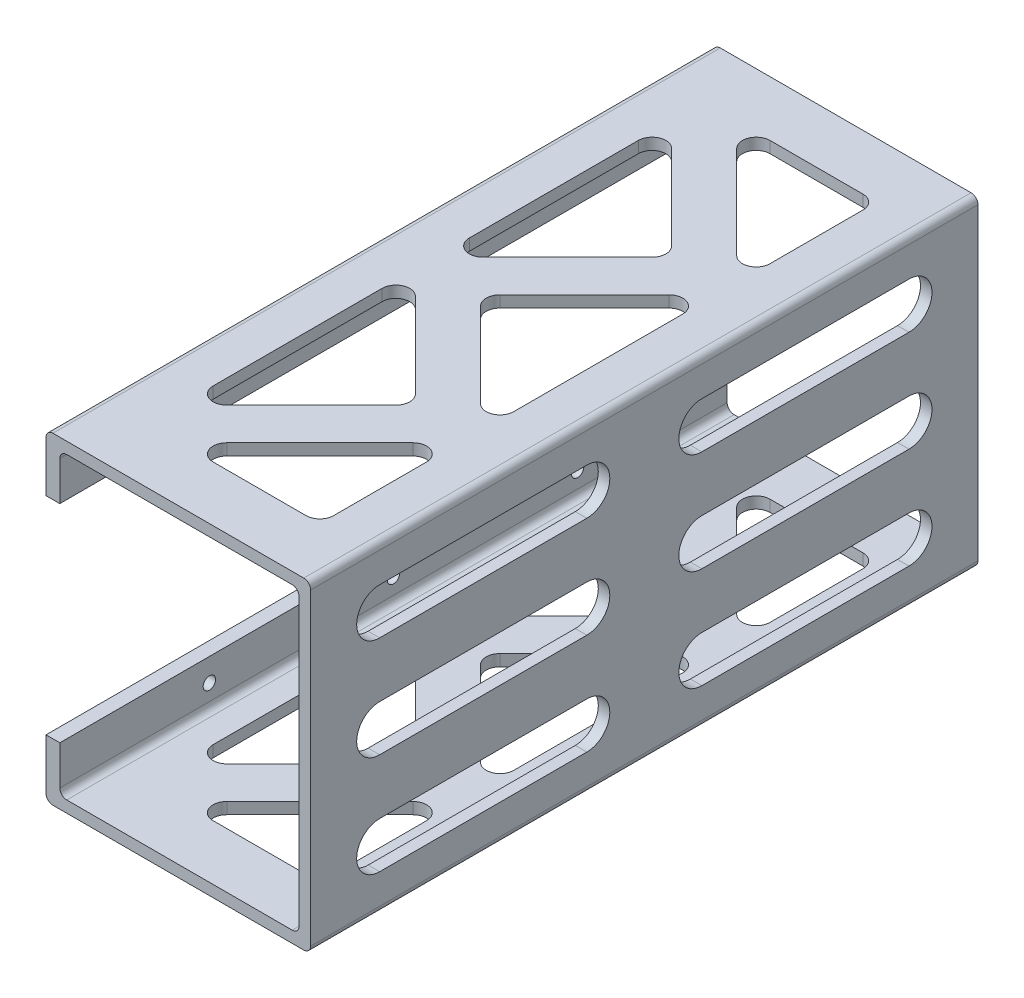
from build123d import *

# Parameters (mm, degrees)
EXTRUDE_1_DEPTH     = 145
SKETCH_2_R          = 1.35
CUT_EXTRUDE_1_DEPTH = 3
CUT_EXTRUDE_2_DEPTH = 2.5
CUT_EXTRUDE_3_DEPTH = 70
FILLET_1_R          = 3
FILLET_2_R          = 1.5


with BuildPart() as part:
    # 草图1 → 凸台-拉伸1 (new body)
    with BuildSketch(Plane.XY):
        Polygon((0, 57.5), (0, 70), (57.5, 70), (57.5, 0), (0, 0), (0, 12.5), (3, 12.5), (3, 2.5), (55, 2.5), (55, 67.5), (3, 67.5), (3, 57.5), align=None)
    extrude(amount=-EXTRUDE_1_DEPTH)

    # 草图2 → 切除-拉伸1 (cut)
    with BuildSketch(Plane.ZY):
        with Locations((-112.5, 62.5)):
            Circle(SKETCH_2_R)
        with Locations((-72.5, 62.5)):
            Circle(SKETCH_2_R)
        with Locations((-32.5, 62.5)):
            Circle(SKETCH_2_R)
        with Locations((-32.5, 7.5)):
            Circle(SKETCH_2_R)
        with Locations((-72.5, 7.5)):
            Circle(SKETCH_2_R)
        with Locations((-112.5, 7.5)):
            Circle(SKETCH_2_R)
    extrude(amount=-CUT_EXTRUDE_1_DEPTH, mode=Mode.SUBTRACT)

    # 草图3 → 切除-拉伸2 (cut)
    with BuildSketch(Plane.ZY.offset(-55)):
        with BuildLine():
            Line((-130, 62), (-85, 62))
            ThreePointArc((-85, 62), (-80, 57), (-85, 52))
            Line((-85, 52), (-130, 52))
            ThreePointArc((-130, 52), (-135, 57), (-130, 62))
        make_face()
        with BuildLine():
            Line((-130, 40), (-85, 40))
            ThreePointArc((-85, 40), (-80, 35), (-85, 30))
            Line((-85, 30), (-130, 30))
            ThreePointArc((-130, 30), (-135, 35), (-130, 40))
        make_face()
        with BuildLine():
            Line((-130, 18), (-85, 18))
            ThreePointArc((-85, 18), (-80, 13), (-85, 8))
            Line((-85, 8), (-130, 8))
            ThreePointArc((-130, 8), (-135, 13), (-130, 18))
        make_face()
        with BuildLine():
            Line((-60, 62), (-15, 62))
            ThreePointArc((-15, 62), (-10, 57), (-15, 52))
            Line((-15, 52), (-60, 52))
            ThreePointArc((-60, 52), (-65, 57), (-60, 62))
        make_face()
        with BuildLine():
            Line((-60, 40), (-15, 40))
            ThreePointArc((-15, 40), (-10, 35), (-15, 30))
            Line((-15, 30), (-60, 30))
            ThreePointArc((-60, 30), (-65, 35), (-60, 40))
        make_face()
        with BuildLine():
            Line((-60, 18), (-15, 18))
            ThreePointArc((-15, 18), (-10, 13), (-15, 8))
            Line((-15, 8), (-60, 8))
            ThreePointArc((-60, 8), (-65, 13), (-60, 18))
        make_face()
    extrude(amount=-CUT_EXTRUDE_2_DEPTH, mode=Mode.SUBTRACT)

    # 草图4 → 切除-拉伸3 (cut)
    with BuildSketch(Plane(origin=(0, 70, 0), x_dir=(1, 0, 0), z_dir=(0, 1, 0))):
        Polygon((47.5, 98.095598855), (21.904401145, 72.5), (47.5, 46.904401145), align=None)
        Polygon((17.071067812, 133), (47.5, 102.571067812), (47.5, 133), align=None)
        Polygon((10, 125.928932188), (35.595598855, 100.333333333), (10, 74.737734479), align=None)
        Polygon((10, 70.262265521), (35.595598855, 44.666666667), (10, 19.071067812), align=None)
        Polygon((17.071067812, 12), (47.5, 42.428932188), (47.5, 12), align=None)
    extrude(amount=-CUT_EXTRUDE_3_DEPTH, mode=Mode.SUBTRACT)

    # 圆角1
    fillet_1_edges = [part.edges().sort_by_distance(p)[0] for p in [
        (17.071067812, 1.25, -133),
        (47.5, 1.25, -133),
        (47.5, 1.25, -102.571067812),
        (17.071067812, 68.75, -133),
        (47.5, 68.75, -133),
        (47.5, 68.75, -102.571067812),
        (47.5, 1.25, -98.095598855),
        (47.5, 1.25, -46.904401145),
        (21.904401145, 1.25, -72.5),
        (47.5, 68.75, -98.095598855),
        (47.5, 68.75, -46.904401145),
        (21.904401145, 68.75, -72.5),
        (10, 1.25, -74.737734479),
        (10, 1.25, -125.928932188),
        (35.595598855, 1.25, -100.333333333),
        (10, 68.75, -74.737734479),
        (10, 68.75, -125.928932188),
        (35.595598855, 68.75, -100.333333333),
        (10, 1.25, -19.071067812),
        (10, 1.25, -70.262265521),
        (35.595598855, 1.25, -44.666666667),
        (10, 68.75, -19.071067812),
        (10, 68.75, -70.262265521),
        (35.595598855, 68.75, -44.666666667),
        (47.5, 1.25, -12),
        (17.071067812, 1.25, -12),
        (47.5, 1.25, -42.428932188),
        (47.5, 68.75, -12),
        (17.071067812, 68.75, -12),
        (47.5, 68.75, -42.428932188),
    ]]
    fillet(fillet_1_edges, radius=FILLET_1_R)

    # 圆角2
    fillet_2_edges = [part.edges().sort_by_distance(p)[0] for p in [
        (0, 70, -72.5),
        (57.5, 70, -72.5),
        (57.5, 0, -72.5),
        (0, 0, -72.5),
        (3, 2.5, -72.5),
        (55, 2.5, -72.5),
        (55, 67.5, -72.5),
        (3, 67.5, -72.5),
    ]]
    fillet(fillet_2_edges, radius=FILLET_2_R)


solid = part.part
